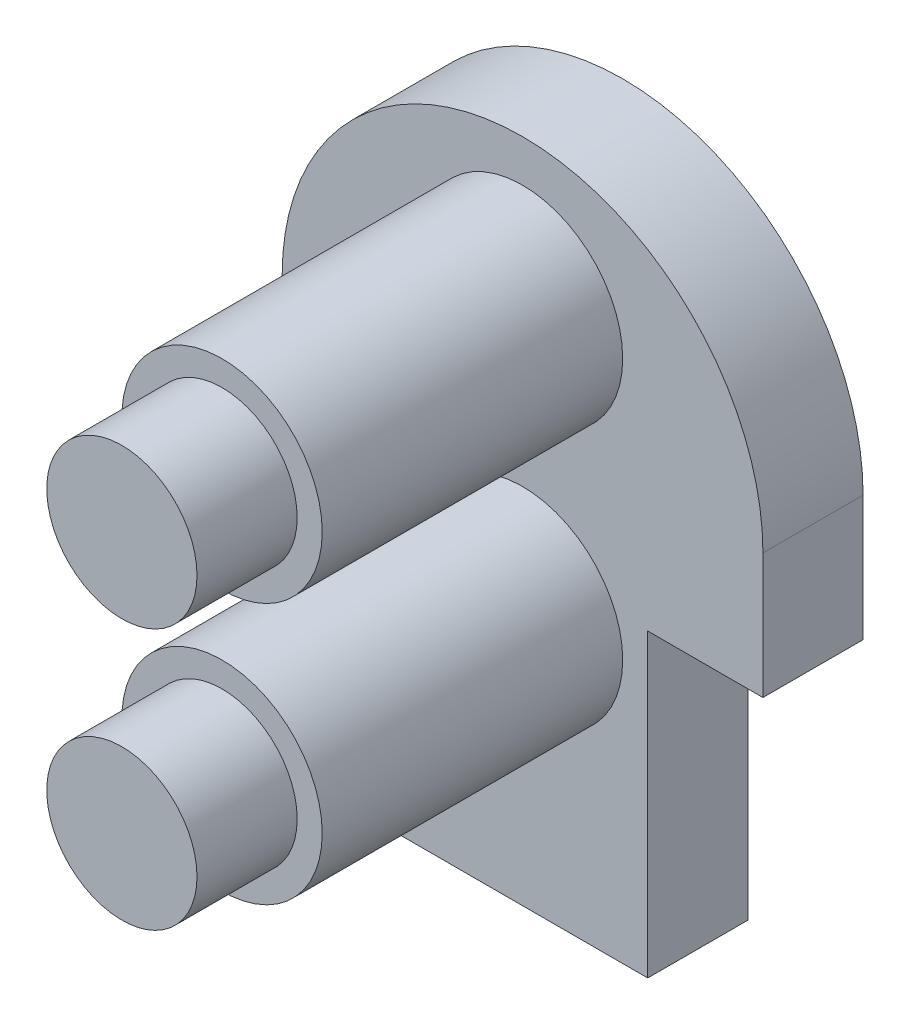
from build123d import *

# Parameters (mm, degrees)
BOSS_EXTRUDE1_DEPTH = 4
SKETCH2_W           = 2.5
SKETCH2_H           = 4
CUT_EXTRUDE1_DEPTH  = 4
SKETCH4_R           = 4
BOSS_EXTRUDE2_DEPTH = 16
SKETCH5_R           = 3
BOSS_EXTRUDE3_DEPTH = 4


with BuildPart() as part:
    # Sketch1 → Boss-Extrude1 (new body)
    with BuildSketch(Plane.XY):
        with BuildLine():
            Line((0, 0), (10, 0))
            Line((10, 0), (10, 4))
            Line((10, 4), (12.5, 4))
            Line((12.5, 4), (12.5, 8))
            Line((12.5, 8), (10, 8))
            Line((10, 8), (10, 12))
            Line((10, 12), (14.6, 12))
            Line((14.6, 12), (14.6, 17))
            ThreePointArc((14.6, 17), (5, 26.6), (-4.6, 17))
            Line((-4.6, 17), (-4.6, 12))
            Line((-4.6, 12), (0, 12))
            Line((0, 12), (0, 8))
            Line((0, 8), (-2.5, 8))
            Line((-2.5, 8), (-2.5, 4))
            Line((-2.5, 4), (0, 4))
            Line((0, 4), (0, 0))
        make_face()
    extrude(amount=BOSS_EXTRUDE1_DEPTH)

    # Sketch2 → Cut-Extrude1 (cut)
    with BuildSketch(Plane.XY.offset(4)):
        with Locations((-1.25, 6)):
            Rectangle(SKETCH2_W, SKETCH2_H)
        with Locations((11.25, 6)):
            Rectangle(SKETCH2_W, SKETCH2_H)
    extrude(amount=-CUT_EXTRUDE1_DEPTH, mode=Mode.SUBTRACT)

    # Sketch4 → Boss-Extrude2 (add)
    with BuildSketch(Plane.XY):
        with Locations((5, 20.921172359)):
            Circle(SKETCH4_R)
        with Locations((5, 10.5)):
            Circle(SKETCH4_R)
    extrude(amount=BOSS_EXTRUDE2_DEPTH)

    # Sketch5 → Boss-Extrude3 (add)
    with BuildSketch(Plane.XY.offset(16)):
        with Locations((5, 10.5)):
            Circle(SKETCH5_R)
        with Locations((5, 20.921172359)):
            Circle(SKETCH5_R)
    extrude(amount=BOSS_EXTRUDE3_DEPTH)


solid = part.part
